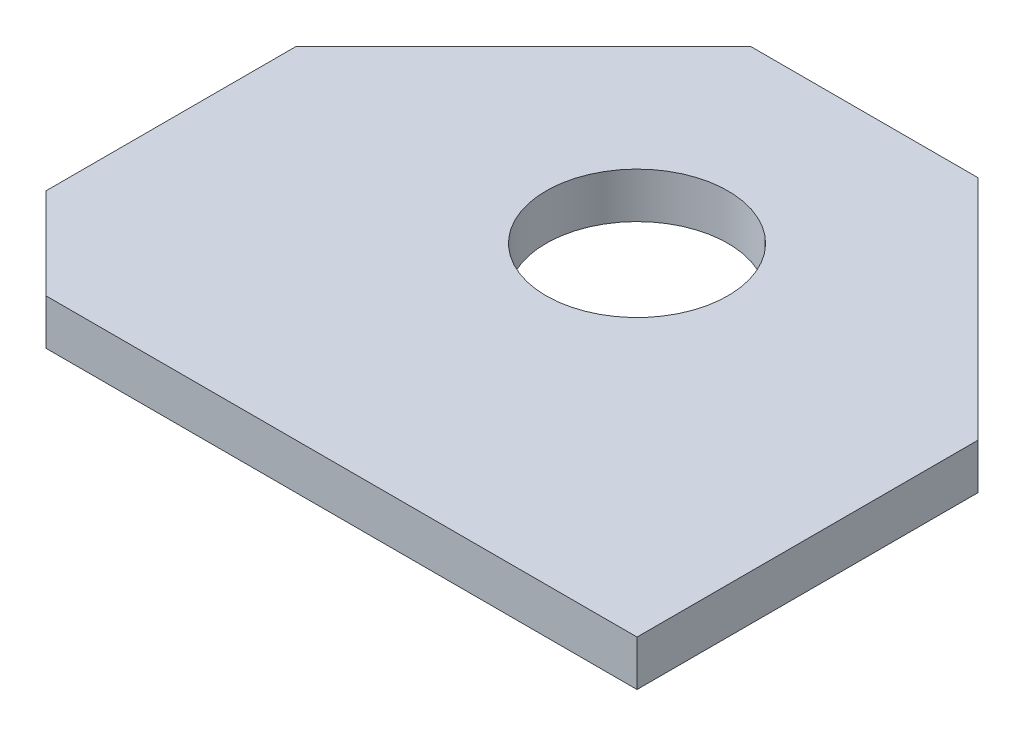
from build123d import *

# Parameters (mm, degrees)
SKETCH1_R           = 4
BOSS_EXTRUDE1_DEPTH = 1
CHAMFER1_SIZE       = 4


with BuildPart() as part:
    # Sketch1 → Boss-Extrude1 (new body, symmetric)
    with BuildSketch(Plane(origin=(0, 0, 0), x_dir=(1, 0, 0), z_dir=(0, 1, 0))):
        Polygon((5, 12.5), (-5, 12.5), (-15, 2.5), (-15, -12.5), (15, -12.5), (15, 2.5), align=None)
        with Locations((0, 2.5)):
            Circle(SKETCH1_R, mode=Mode.SUBTRACT)
    extrude(amount=BOSS_EXTRUDE1_DEPTH, both=True)

    # Chamfer1
    chamfer1_edges = [part.edges().sort_by_distance(p)[0] for p in [
        (-15, 0, 12.5),
    ]]
    chamfer(chamfer1_edges, length=CHAMFER1_SIZE)


solid = part.part
